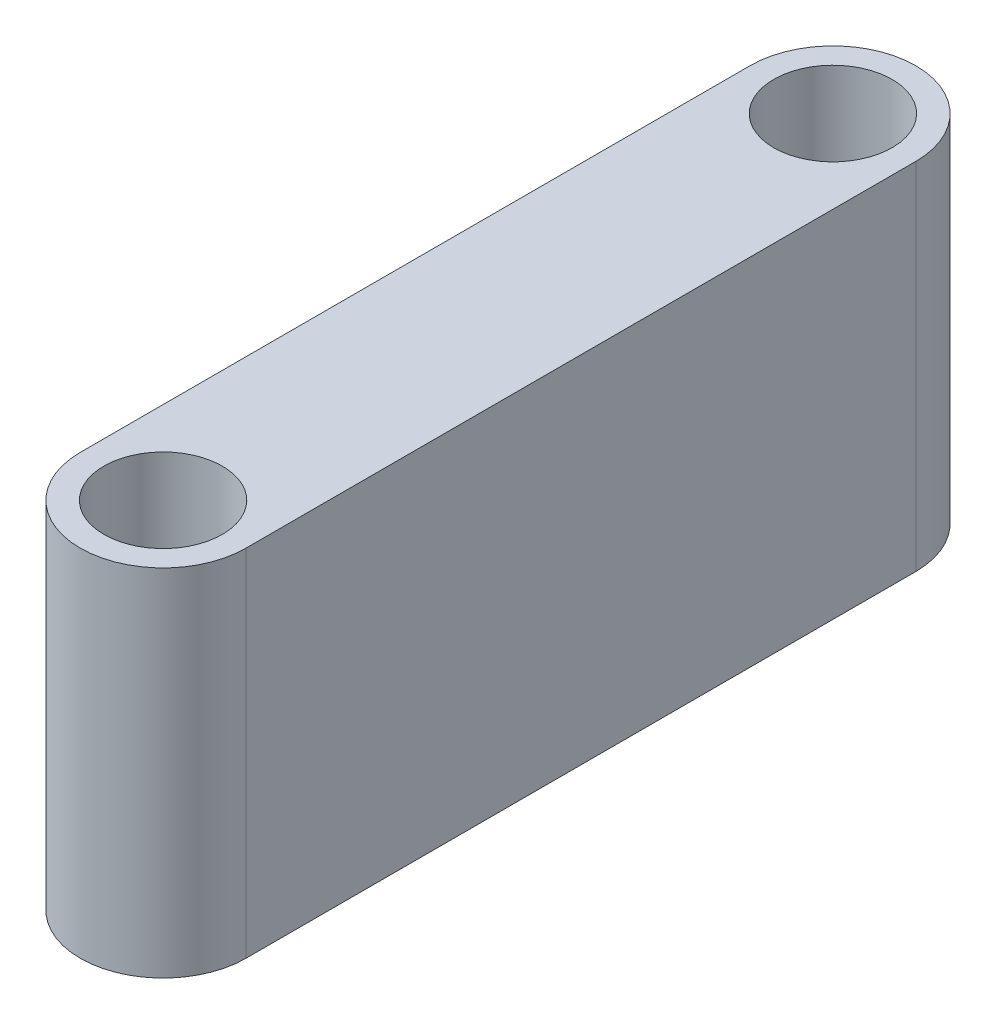
from build123d import *

# Parameters (mm, degrees)
SKETCH2_R           = 3.175
BOSS_EXTRUDE1_DEPTH = 9.525
SKETCH3_R           = 1.95
CUT_EXTRUDE1_DEPTH  = 5.8


with BuildPart() as part:
    # Sketch2 → Boss-Extrude1 (new body, symmetric)
    with BuildSketch(Plane(origin=(0, 0, 0), x_dir=(1, 0, 0), z_dir=(0, 1, 0))):
        with BuildLine():
            Line((13.515512242, 17.960512242), (13.515512242, -17.960512242))
            ThreePointArc((13.515512242, -17.960512242), (17.960512242, -22.405512242), (22.405512242, -17.960512242))
            Line((22.405512242, -17.960512242), (22.405512242, 17.960512242))
            ThreePointArc((22.405512242, 17.960512242), (17.960512242, 22.405512242), (13.515512242, 17.960512242))
        make_face()
        with Locations((17.960512242, -17.960512242)):
            Circle(SKETCH2_R, mode=Mode.SUBTRACT)
        with Locations((17.960512242, 17.960512242)):
            Circle(SKETCH2_R, mode=Mode.SUBTRACT)
    extrude(amount=BOSS_EXTRUDE1_DEPTH, both=True)

    # Sketch3 → Cut-Extrude1 (cut)
    with BuildSketch(Plane.ZY.offset(-13.515512242)):
        with Locations((-9.97, 6.25)):
            Circle(SKETCH3_R)
        with Locations((9.97, 6.25)):
            Circle(SKETCH3_R)
        with Locations((9.97, -6.25)):
            Circle(SKETCH3_R)
        with Locations((-9.97, -6.25)):
            Circle(SKETCH3_R)
    extrude(amount=-CUT_EXTRUDE1_DEPTH, mode=Mode.SUBTRACT)


solid = part.part
